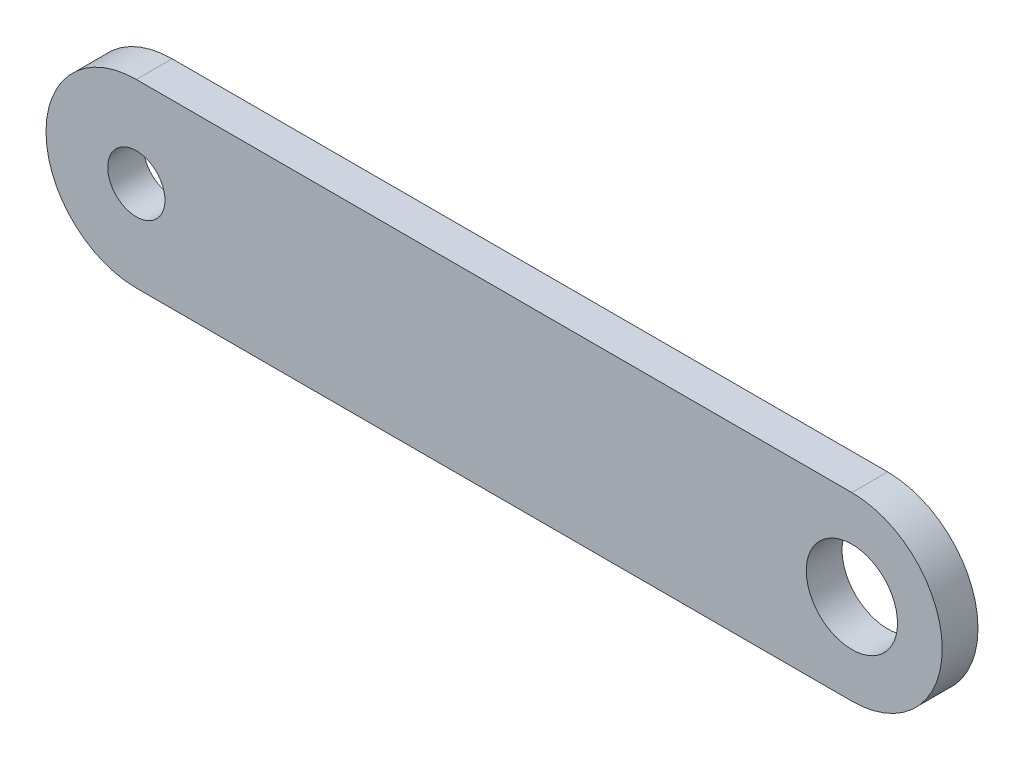
from build123d import *

# Parameters (mm, degrees)
SKETCH_1_R      = 1.6
SKETCH_1_R_2    = 2.55
EXTRUDE_1_DEPTH = 2


with BuildPart() as part:
    # 草图1 → 凸台-拉伸1 (new body)
    with BuildSketch(Plane.XY):
        with BuildLine():
            Line((-20, 5.05), (20, 5.05))
            ThreePointArc((20, 5.05), (25.05, 0), (20, -5.05))
            Line((20, -5.05), (-20, -5.05))
            ThreePointArc((-20, -5.05), (-25.05, 0), (-20, 5.05))
        make_face()
        with Locations((-20, 0)):
            Circle(SKETCH_1_R, mode=Mode.SUBTRACT)
        with Locations((20, 0)):
            Circle(SKETCH_1_R_2, mode=Mode.SUBTRACT)
    extrude(amount=EXTRUDE_1_DEPTH)


solid = part.part
